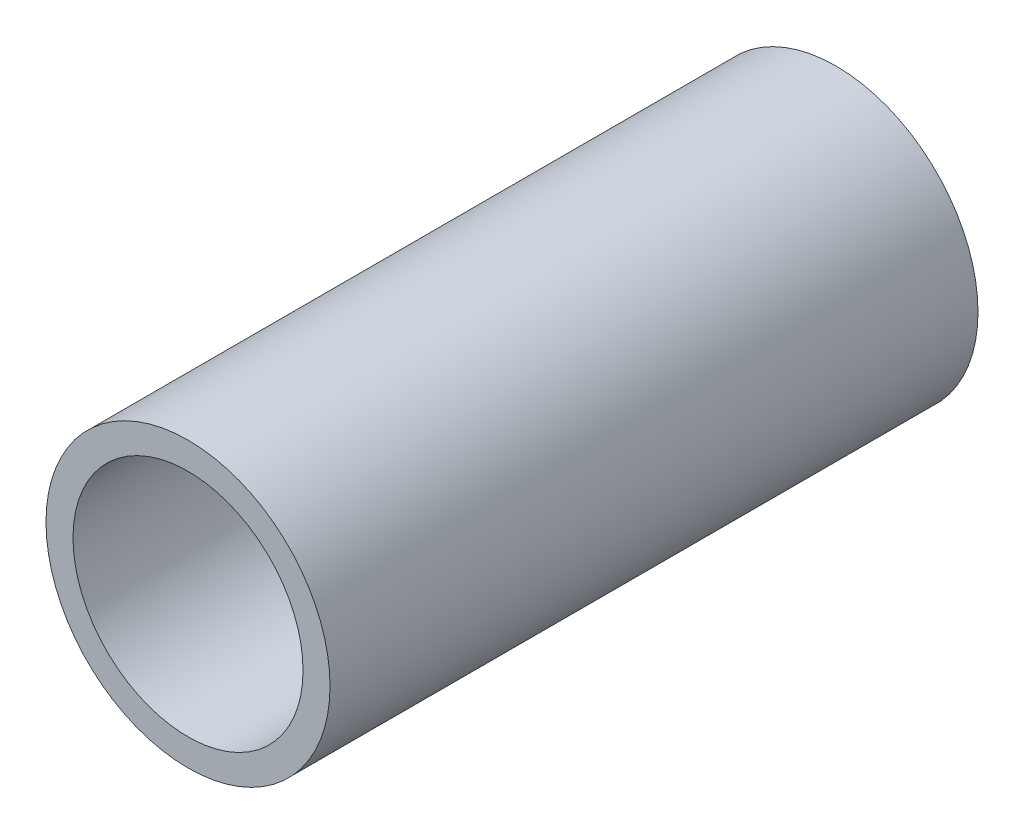
from build123d import *

# Parameters (mm, degrees)
SKETCH1_R           = 16.7005
SKETCH1_R_2         = 13.5255
BOSS_EXTRUDE1_DEPTH = 76.2


with BuildPart() as part:
    # Sketch1 → Boss-Extrude1 (new body)
    with BuildSketch(Plane.XY):
        Circle(SKETCH1_R)
        Circle(SKETCH1_R_2, mode=Mode.SUBTRACT)
    extrude(amount=BOSS_EXTRUDE1_DEPTH)


solid = part.part
